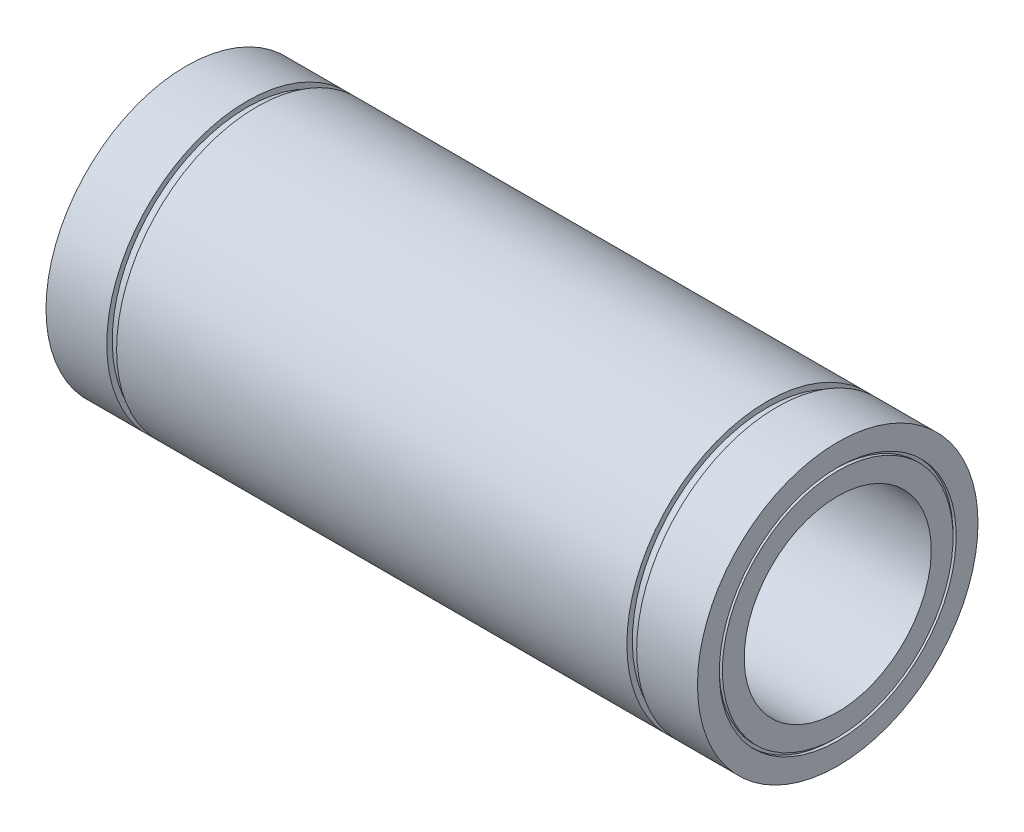
from build123d import *


with BuildPart() as part:
    # Esboço1 → Revolução1 (revolve)
    with BuildSketch(Plane.XY):
        Polygon((-104.5, 45), (-85, 45), (-85, 43.25), (-81.85, 43.25), (-81.85, 45), (81.85, 45), (81.85, 43.25), (85, 43.25), (85, 45), (104.5, 45), (104.5, 38), (103.5, 38), (103.5, 37), (104.5, 37), (104.5, 30), (-104.5, 30), (-104.5, 37), (-103.5, 37), (-103.5, 38), (-104.5, 38), align=None)
    revolve(axis=Axis((0, 0, 0), (-1, 0, 0)))


solid = part.part
